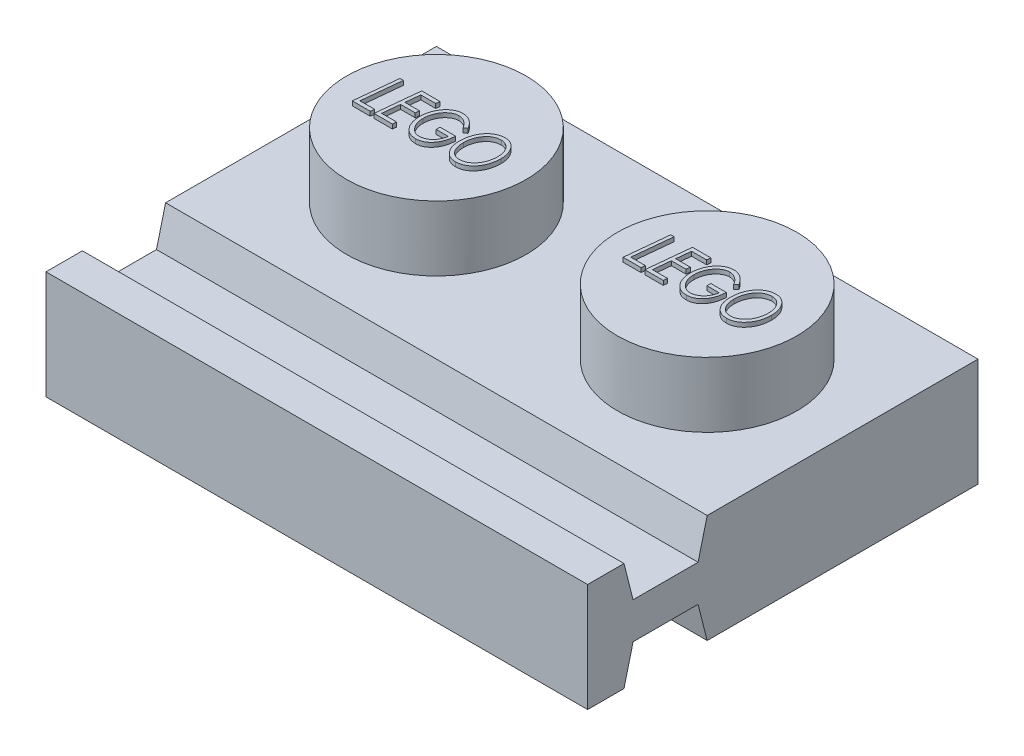
from build123d import *

# Parameters (mm, degrees)
SKETCH2_W           = 15.875
SKETCH2_H           = 7.9375
BOSS_EXTRUDE3_DEPTH = 3.175
SKETCH3_R           = 2.630752939
BOSS_EXTRUDE4_DEPTH = 1.905
LPATTERN1_COUNT     = 2
LPATTERN1_PITCH     = 7.9375
SHELL1_T            = -1.524
BOSS_EXTRUDE5_DEPTH = 0.127
LPATTERN2_COUNT     = 2
LPATTERN2_PITCH     = 7.9375
SKETCH5_R           = 1.4986
SKETCH5_R_2         = 0.635
BOSS_EXTRUDE6_DEPTH = 1.651
BOSS_EXTRUDE7_DEPTH = 15.875


with BuildPart() as part:
    # Sketch2 → Boss-Extrude3 (new body)
    with BuildSketch(Plane(origin=(0, 0, 0), x_dir=(1, 0, 0), z_dir=(0, 1, 0))):
        with Locations((-9.795613381, 4.754641089)):
            Rectangle(SKETCH2_W, SKETCH2_H)
    extrude(amount=BOSS_EXTRUDE3_DEPTH)

    # Sketch3 → Boss-Extrude4 (add)
    with BuildSketch(Plane(origin=(0, 3.175, 0), x_dir=(1, 0, 0), z_dir=(0, 1, 0))):
        with Locations((-13.764363381, 4.754641089)):
            Circle(SKETCH3_R)
    boss_extrude4 = extrude(amount=BOSS_EXTRUDE4_DEPTH)

    # LPattern1: Boss-Extrude4 ×2
    with Locations(*[(i * LPATTERN1_PITCH, 0, 0) for i in range(1, LPATTERN1_COUNT)]):
        add(boss_extrude4)

    # Shell1
    shell1_openings = [part.faces().sort_by_distance(p)[0] for p in [
        (-9.795613381, 0, -4.754641089),
    ]]
    offset(amount=SHELL1_T, openings=shell1_openings, kind=Kind.INTERSECTION)

    # Sketch4 → Boss-Extrude5 (add)
    with BuildSketch(Plane(origin=(0, 5.08, 0), x_dir=(1, 0, 0), z_dir=(0, 1, 0))):
        Polygon((-15.421955913, 5.34660841), (-15.323500384, 5.34660841), (-15.441290849, 4.190582769), (-15.01414141, 4.190582769), (-15.02533532, 4.07660841), (-15.551449102, 4.07660841), align=None)
        Polygon((-14.248885, 5.34660841), (-14.262877387, 5.232634051), (-14.699694294, 5.232634051), (-14.742943493, 4.809300718), (-14.314013205, 4.809300718), (-14.326733557, 4.695326359), (-14.754646217, 4.695326359), (-14.806036442, 4.190582769), (-14.362859359, 4.190582769), (-14.374307676, 4.07660841), (-14.916449102, 4.07660841), (-14.786701506, 5.34660841), align=None)
        with BuildLine():
            Line((-13.157987564, 5.079226599), (-13.23685375, 5.004685333))
            add(Edge.make_bspline(
                [(-13.23685375, 5.004685333), (-13.243036349, 5.014919943), (-13.255215537, 5.03508124), (-13.274843903, 5.0639219), (-13.295404966, 5.090766309), (-13.316668722, 5.115943823), (-13.338681843, 5.139287343), (-13.361588027, 5.160749301), (-13.385450265, 5.180091456), (-13.409701872, 5.197942406), (-13.434658284, 5.213660022), (-13.459747782, 5.227481566), (-13.485177989, 5.238904833), (-13.510565197, 5.248734726), (-13.536282118, 5.256136896), (-13.562187777, 5.261089256), (-13.588089761, 5.264689825), (-13.605477312, 5.265029123), (-13.614139407, 5.265198154)],
                knots=[0, 0, 0, 0, 3.5867e-05, 7.0655e-05, 0.000104594, 0.000137266, 0.00016948, 0.0002008, 0.000231355, 0.000261581, 0.000291084, 0.000319773, 0.000347439, 0.000374655, 0.000401388, 0.000427582, 0.000453742, 0.000479711, 0.000479711, 0.000479711, 0.000479711], degree=3))
            add(Edge.make_bspline(
                [(-13.614139407, 5.265198154), (-13.623817018, 5.264942089), (-13.643246281, 5.264428001), (-13.672242613, 5.260605848), (-13.70083591, 5.253771652), (-13.729278127, 5.244988175), (-13.757272205, 5.233098144), (-13.785048709, 5.218900423), (-13.812373825, 5.20184576), (-13.839460855, 5.182752056), (-13.865426178, 5.16117013), (-13.890266569, 5.13792049), (-13.91359838, 5.112994152), (-13.935710508, 5.086452282), (-13.955872189, 5.057845897), (-13.975112242, 5.027830316), (-13.992587445, 4.995991744), (-14.008566347, 4.962671117), (-14.023015409, 4.928317995), (-14.035508966, 4.893155428), (-14.045942052, 4.857372561), (-14.054589121, 4.820944025), (-14.06149942, 4.783854091), (-14.066312673, 4.746142046), (-14.069143076, 4.707836031), (-14.069568079, 4.682101861), (-14.069782435, 4.669122433)],
                knots=[0, 0, 0, 0, 2.903e-05, 5.8283e-05, 8.7534e-05, 0.000117144, 0.000147477, 0.000178653, 0.000210636, 0.000244026, 0.000278, 0.000311837, 0.000346034, 0.000380367, 0.000415383, 0.000450953, 0.000487277, 0.000524259, 0.000561774, 0.000599029, 0.000636142, 0.000673537, 0.00071131, 0.000749271, 0.000787535, 0.000826472, 0.000826472, 0.000826472, 0.000826472], degree=3))
            add(Edge.make_bspline(
                [(-14.069782435, 4.669122433), (-14.069477418, 4.651721569), (-14.068877636, 4.617504752), (-14.063037479, 4.567164063), (-14.053971473, 4.518756671), (-14.041310983, 4.472223428), (-14.024646127, 4.42784351), (-14.004569657, 4.385349364), (-13.980409537, 4.345047805), (-13.953305264, 4.306998763), (-13.923509762, 4.272231716), (-13.891611692, 4.241833165), (-13.858241554, 4.215836332), (-13.822960448, 4.194859762), (-13.786317389, 4.177985595), (-13.747701019, 4.166780357), (-13.707804487, 4.159194772), (-13.680575585, 4.158413751), (-13.666801666, 4.158018667)],
                knots=[0, 0, 0, 0, 5.2184e-05, 0.000102614, 0.000151811, 0.000199829, 0.000247083, 0.000293853, 0.000340625, 0.000387856, 0.000433855, 0.000477763, 0.000519845, 0.000560465, 0.000600659, 0.0006405, 0.000680822, 0.0007221, 0.0007221, 0.0007221, 0.0007221], degree=3))
            add(Edge.make_bspline(
                [(-13.666801666, 4.158018667), (-13.650119891, 4.158598006), (-13.616764989, 4.159756384), (-13.567583001, 4.170959003), (-13.519199429, 4.187625511), (-13.472815147, 4.211693168), (-13.428975753, 4.24107788), (-13.3888146, 4.275137052), (-13.353443755, 4.314132031), (-13.322014522, 4.35741319), (-13.295472287, 4.406100752), (-13.27204085, 4.459501556), (-13.253441597, 4.518549092), (-13.244174766, 4.559989791), (-13.23939782, 4.581352)],
                knots=[0, 0, 0, 0, 4.9973e-05, 9.9921e-05, 0.000150611, 0.000203177, 0.000256167, 0.000308679, 0.000360721, 0.000413748, 0.000468753, 0.000526746, 0.000588456, 0.000654111, 0.000654111, 0.000654111, 0.000654111], degree=3))
            Line((-13.23939782, 4.581352), (-13.597602948, 4.581352))
            Line((-13.597602948, 4.581352), (-13.597602948, 4.695326359))
            Line((-13.597602948, 4.695326359), (-13.141705512, 4.695326359))
            add(Edge.make_bspline(
                [(-13.141705512, 4.695326359), (-13.143220249, 4.671630935), (-13.14618471, 4.625257073), (-13.156473523, 4.557663764), (-13.169882793, 4.493369383), (-13.188032162, 4.432650411), (-13.210191974, 4.37537214), (-13.236456597, 4.321477624), (-13.266757599, 4.270933421), (-13.300959259, 4.224225256), (-13.338414001, 4.182195788), (-13.37822362, 4.145176879), (-13.420442551, 4.113917018), (-13.464913787, 4.088167818), (-13.511934995, 4.06856876), (-13.561029266, 4.05415967), (-13.612484302, 4.045619356), (-13.647519936, 4.044574047), (-13.665275224, 4.044044308)],
                knots=[0, 0, 0, 0, 7.12e-05, 0.000139344, 0.00020491, 0.000268096, 0.00032923, 0.000388964, 0.000447735, 0.000505793, 0.000562373, 0.000616384, 0.000668589, 0.000719646, 0.000770156, 0.000821037, 0.000872858, 0.000926102, 0.000926102, 0.000926102, 0.000926102], degree=3))
            add(Edge.make_bspline(
                [(-13.665275224, 4.044044308), (-13.683458795, 4.044552296), (-13.719178417, 4.045550182), (-13.771372456, 4.054296421), (-13.821069071, 4.067841152), (-13.868065514, 4.087506656), (-13.912556407, 4.112374207), (-13.953984263, 4.143464588), (-13.993154071, 4.179412869), (-14.029026836, 4.220871562), (-14.061293356, 4.26652386), (-14.090007965, 4.315160597), (-14.113916063, 4.366865748), (-14.133555901, 4.421262957), (-14.148827293, 4.478548833), (-14.159713516, 4.538607223), (-14.166095756, 4.601566492), (-14.167008525, 4.644430286), (-14.167474743, 4.666323955)],
                knots=[0, 0, 0, 0, 5.4515e-05, 0.000107089, 0.00015832, 0.000208732, 0.000259537, 0.000310826, 0.000363759, 0.000418756, 0.000474947, 0.000531277, 0.000587959, 0.00064558, 0.000704576, 0.000765604, 0.000828511, 0.000894188, 0.000894188, 0.000894188, 0.000894188], degree=3))
            add(Edge.make_bspline(
                [(-14.167474743, 4.666323955), (-14.167185589, 4.682101713), (-14.16661133, 4.713436248), (-14.163381594, 4.759994442), (-14.157432775, 4.805749539), (-14.149274332, 4.850644315), (-14.139160769, 4.894945835), (-14.126422318, 4.938327925), (-14.111352878, 4.98094547), (-14.094155797, 5.022494256), (-14.074869439, 5.062577802), (-14.053847868, 5.100800933), (-14.03078607, 5.136684011), (-14.006484206, 5.170754132), (-13.979939226, 5.202226268), (-13.951836475, 5.231556391), (-13.922318071, 5.259016319), (-13.890824475, 5.283795413), (-13.858123028, 5.306042524), (-13.824881044, 5.325834039), (-13.790743443, 5.34211596), (-13.756112763, 5.355771227), (-13.720646944, 5.366079712), (-13.684726153, 5.373904452), (-13.648081628, 5.378221983), (-13.623478046, 5.378854133), (-13.611086522, 5.379172513)],
                knots=[0, 0, 0, 0, 4.7337e-05, 9.4011e-05, 0.000139924, 0.000185684, 0.000230857, 0.000276183, 0.000321242, 0.000366409, 0.000411014, 0.000454628, 0.000497184, 0.000538913, 0.000580086, 0.000620572, 0.000660721, 0.00070093, 0.000740658, 0.000779316, 0.000816866, 0.000854, 0.000890868, 0.000927543, 0.000964179, 0.001001354, 0.001001354, 0.001001354, 0.001001354], degree=3))
            add(Edge.make_bspline(
                [(-13.611086522, 5.379172513), (-13.599885481, 5.378887615), (-13.577690409, 5.378323085), (-13.544759644, 5.375041802), (-13.512580278, 5.369229816), (-13.481226926, 5.36060081), (-13.450309917, 5.350370482), (-13.420236456, 5.337162127), (-13.39072561, 5.322040578), (-13.362124517, 5.304229546), (-13.334002379, 5.284471776), (-13.306931369, 5.261858803), (-13.280001622, 5.237508559), (-13.254169985, 5.210414835), (-13.228831131, 5.181124192), (-13.20464202, 5.149192743), (-13.18043895, 5.115396141), (-13.16557029, 5.091442492), (-13.157987564, 5.079226599)],
                knots=[0, 0, 0, 0, 3.3606e-05, 6.6591e-05, 9.9176e-05, 0.000131574, 0.000164077, 0.000196781, 0.000230006, 0.000263473, 0.000297779, 0.000333024, 0.000369219, 0.000406644, 0.000445248, 0.000485345, 0.000526779, 0.000569901, 0.000569901, 0.000569901, 0.000569901], degree=3))
        make_face()
        with BuildLine():
            add(Edge.make_bspline(
                [(-12.369325705, 5.379172513), (-12.353010143, 5.378720522), (-12.32085994, 5.377829863), (-12.273715249, 5.369659659), (-12.22864765, 5.356507424), (-12.185856311, 5.337650018), (-12.145072326, 5.313842859), (-12.10647493, 5.284550539), (-12.070049375, 5.250024202), (-12.036169842, 5.210647693), (-12.00531375, 5.167406166), (-11.978235129, 5.120902684), (-11.955360597, 5.071642915), (-11.936357429, 5.019696609), (-11.921887955, 4.964835989), (-11.911994605, 4.907187182), (-11.905270318, 4.84685662), (-11.904608097, 4.805673345), (-11.904269615, 4.784623234)],
                knots=[0, 0, 0, 0, 4.8912e-05, 9.6383e-05, 0.000143072, 0.00018944, 0.000236302, 0.000284436, 0.000334467, 0.000386593, 0.000440034, 0.000493616, 0.000547793, 0.000602762, 0.000659349, 0.000717739, 0.000778115, 0.000841241, 0.000841241, 0.000841241, 0.000841241], degree=3))
            add(Edge.make_bspline(
                [(-11.904269615, 4.784623234), (-11.904724813, 4.758992871), (-11.905619371, 4.708623908), (-11.913649979, 4.634691374), (-11.926918957, 4.563951657), (-11.945042207, 4.49615546), (-11.969268607, 4.431731122), (-11.997812291, 4.369990143), (-12.032508136, 4.311855249), (-12.071636526, 4.257287391), (-12.11438555, 4.207292778), (-12.160684455, 4.163785264), (-12.209491268, 4.12681072), (-12.260952984, 4.096525947), (-12.315022525, 4.072933007), (-12.371712054, 4.05602052), (-12.43112154, 4.045889546), (-12.47164277, 4.044665448), (-12.49220431, 4.044044308)],
                knots=[0, 0, 0, 0, 7.6873e-05, 0.000151071, 0.000222773, 0.000292635, 0.000361299, 0.000429016, 0.000496426, 0.000564063, 0.000630262, 0.000693435, 0.00075429, 0.000813586, 0.000872147, 0.000930825, 0.000990675, 0.00105233, 0.00105233, 0.00105233, 0.00105233], degree=3))
            add(Edge.make_bspline(
                [(-12.49220431, 4.044044308), (-12.509616292, 4.04451494), (-12.543682005, 4.04543571), (-12.593480052, 4.053188575), (-12.640452828, 4.066244037), (-12.684989099, 4.084066344), (-12.726670432, 4.107489433), (-12.765818741, 4.135865921), (-12.802122503, 4.169487075), (-12.83534682, 4.207966726), (-12.865201071, 4.250535984), (-12.891189794, 4.296615807), (-12.91347966, 4.345682347), (-12.931507817, 4.398084844), (-12.945433182, 4.453595942), (-12.955221104, 4.512216375), (-12.961524863, 4.573921358), (-12.962237892, 4.616189815), (-12.962602948, 4.637830365)],
                knots=[0, 0, 0, 0, 5.2215e-05, 0.000102157, 0.000150733, 0.000198212, 0.000245705, 0.000293794, 0.000342944, 0.000393802, 0.000446031, 0.000498666, 0.000552293, 0.000607486, 0.000664684, 0.000723782, 0.000785651, 0.000850556, 0.000850556, 0.000850556, 0.000850556], degree=3))
            add(Edge.make_bspline(
                [(-12.962602948, 4.637830365), (-12.962348656, 4.654713021), (-12.961844621, 4.68817633), (-12.958119133, 4.737832996), (-12.952514622, 4.786550271), (-12.943616351, 4.83402181), (-12.933066316, 4.8806248), (-12.919782503, 4.926031082), (-12.904304725, 4.970508016), (-12.88616901, 5.013561667), (-12.866377445, 5.055186009), (-12.843997862, 5.094446642), (-12.820275911, 5.131646309), (-12.79433308, 5.166341896), (-12.767012283, 5.199072462), (-12.737321482, 5.229081319), (-12.705989763, 5.256911788), (-12.672917443, 5.282323432), (-12.638580562, 5.305193307), (-12.602929741, 5.324828759), (-12.566454338, 5.341794401), (-12.528918438, 5.355489869), (-12.490336002, 5.365956739), (-12.450894272, 5.373598515), (-12.410399159, 5.378302894), (-12.383076102, 5.378881385), (-12.369325705, 5.379172513)],
                knots=[0, 0, 0, 0, 5.0643e-05, 0.00010038, 0.000149323, 0.000197677, 0.000245196, 0.000292617, 0.000339526, 0.000386395, 0.000432706, 0.000477705, 0.000521881, 0.000564978, 0.000607585, 0.000649681, 0.000691492, 0.000733218, 0.000774708, 0.000815134, 0.000855202, 0.000895282, 0.000934843, 0.000975008, 0.001015717, 0.001056959, 0.001056959, 0.001056959, 0.001056959], degree=3))
        make_face()
        with BuildLine():
            add(Edge.make_bspline(
                [(-12.37059774, 5.265198154), (-12.382313596, 5.264974538), (-12.405384953, 5.264534185), (-12.43952799, 5.260405022), (-12.472806234, 5.254641281), (-12.50500305, 5.2453884), (-12.53641925, 5.23449868), (-12.566541003, 5.220073421), (-12.596086752, 5.204049224), (-12.624325369, 5.185085614), (-12.651275466, 5.163901314), (-12.677105719, 5.1407675), (-12.701242778, 5.115240955), (-12.723914887, 5.087622005), (-12.745319033, 5.058107871), (-12.765258418, 5.02643651), (-12.783453767, 4.992497975), (-12.800435903, 4.956872571), (-12.815618513, 4.919838387), (-12.828923446, 4.882001808), (-12.839728639, 4.843441788), (-12.848995625, 4.804516904), (-12.856130352, 4.764939705), (-12.861169544, 4.724771762), (-12.864339072, 4.683929196), (-12.8647191, 4.656492627), (-12.864910641, 4.642664099)],
                knots=[0, 0, 0, 0, 3.5131e-05, 6.9182e-05, 0.000103064, 0.000136333, 0.000169567, 0.000202688, 0.000236393, 0.000270332, 0.000304582, 0.000339169, 0.000374259, 0.000409863, 0.000446299, 0.000483568, 0.000522044, 0.000561759, 0.000601917, 0.000642065, 0.000682008, 0.000721995, 0.000762067, 0.000802584, 0.000843403, 0.000884884, 0.000884884, 0.000884884, 0.000884884], degree=3))
            add(Edge.make_bspline(
                [(-12.864910641, 4.642664099), (-12.864307988, 4.619656102), (-12.863131603, 4.574744224), (-12.854429419, 4.509171597), (-12.839695903, 4.447271889), (-12.822395219, 4.398577377), (-12.806018379, 4.361918699), (-12.792619836, 4.336186177), (-12.777779937, 4.312362342), (-12.762246178, 4.289966829), (-12.745390246, 4.269317365), (-12.727389498, 4.250238819), (-12.708171153, 4.232904881), (-12.688073445, 4.216982903), (-12.666766853, 4.20305699), (-12.644505145, 4.191085763), (-12.621414016, 4.180768501), (-12.597334266, 4.172401088), (-12.572284701, 4.166087649), (-12.546442494, 4.161495703), (-12.519659259, 4.158635539), (-12.50145487, 4.158226513), (-12.49220431, 4.158018667)],
                knots=[0, 0, 0, 0, 6.9012e-05, 0.000134712, 0.000198022, 0.000259579, 0.000289414, 0.000318432, 0.000346532, 0.000373564, 0.000400145, 0.00042642, 0.000452175, 0.000477724, 0.000503267, 0.000528424, 0.00055348, 0.000579065, 0.000604796, 0.000630896, 0.000657755, 0.000685504, 0.000685504, 0.000685504, 0.000685504], degree=3))
            add(Edge.make_bspline(
                [(-12.49220431, 4.158018667), (-12.481164543, 4.158226379), (-12.45926255, 4.158638462), (-12.426815915, 4.163069526), (-12.394912776, 4.169171543), (-12.363753517, 4.178557501), (-12.333054523, 4.1901992), (-12.30315314, 4.204836709), (-12.27362727, 4.221656145), (-12.245054493, 4.241259996), (-12.217396148, 4.263059149), (-12.191102552, 4.2869402), (-12.166751424, 4.31313992), (-12.143343282, 4.340857537), (-12.121926482, 4.370957713), (-12.101553921, 4.402800133), (-12.083509498, 4.437043875), (-12.066362584, 4.472756352), (-12.051268705, 4.510002211), (-12.037904005, 4.548157353), (-12.027111895, 4.587233797), (-12.017881689, 4.626845971), (-12.010718503, 4.667266057), (-12.005706916, 4.708370092), (-12.002526277, 4.750312827), (-12.002151397, 4.778511748), (-12.001961923, 4.79276426)],
                knots=[0, 0, 0, 0, 3.3097e-05, 6.5662e-05, 9.8093e-05, 0.000130454, 0.000163149, 0.000196488, 0.000230221, 0.000265008, 0.000300331, 0.000335806, 0.000371442, 0.000407566, 0.000444563, 0.000482183, 0.000520883, 0.000560598, 0.000600991, 0.00064138, 0.000681813, 0.000722543, 0.000763366, 0.000804893, 0.000846727, 0.000889479, 0.000889479, 0.000889479, 0.000889479], degree=3))
            add(Edge.make_bspline(
                [(-12.001961923, 4.79276426), (-12.002383429, 4.811264), (-12.003207157, 4.847417056), (-12.008729979, 4.900202516), (-12.018384404, 4.949996074), (-12.031884335, 4.996843587), (-12.049147304, 5.040781654), (-12.070413266, 5.081809748), (-12.095511146, 5.119934561), (-12.115257706, 5.142857206), (-12.125094935, 5.15427668)],
                knots=[0, 0, 0, 0, 5.5498e-05, 0.000108457, 0.000158999, 0.000207469, 0.000254523, 0.000300379, 0.00034589, 0.00039107, 0.00039107, 0.00039107, 0.00039107], degree=3))
            add(Edge.make_bspline(
                [(-12.125094935, 5.15427668), (-12.133669324, 5.163096064), (-12.150521626, 5.180429887), (-12.178137379, 5.203115094), (-12.206989058, 5.222389045), (-12.237249627, 5.237947562), (-12.268734009, 5.250365639), (-12.301624315, 5.258916547), (-12.335745739, 5.264150728), (-12.358876291, 5.264845883), (-12.37059774, 5.265198154)],
                knots=[0, 0, 0, 0, 3.6878e-05, 7.2482e-05, 0.000106986, 0.00014078, 0.00017437, 0.000208309, 0.000242526, 0.000277679, 0.000277679, 0.000277679, 0.000277679], degree=3))
        make_face(mode=Mode.SUBTRACT)
    boss_extrude5 = extrude(amount=BOSS_EXTRUDE5_DEPTH)

    # LPattern2: Boss-Extrude5 ×2
    with Locations(*[(i * LPATTERN2_PITCH, 0, 0) for i in range(1, LPATTERN2_COUNT)]):
        add(boss_extrude5)

    # Sketch5 → Boss-Extrude6 (add)
    with BuildSketch(Plane.XZ):
        with Locations((-9.795613381, -4.754641089)):
            Circle(SKETCH5_R)
        with Locations((-9.795613381, -4.754641089)):
            Circle(SKETCH5_R_2, mode=Mode.SUBTRACT)
    extrude(amount=-BOSS_EXTRUDE6_DEPTH)

    # Sketch6 → Boss-Extrude7 (add)
    with BuildSketch(Plane(origin=(-1.858113381, 0, 0), x_dir=(0, 0, -1), z_dir=(1, 0, 0))):
        Polygon((0.785891089, 3.175), (0.785891089, 0), (0.519191089, 1.0541), (-1.385808911, 1.0541), (-1.652508911, 0), (-2.719308911, 0), (-2.719308911, 3.175), (-1.652508911, 3.175), (-1.385808911, 2.1209), (0.519191089, 2.1209), align=None)
    extrude(amount=-BOSS_EXTRUDE7_DEPTH)


solid = part.part
